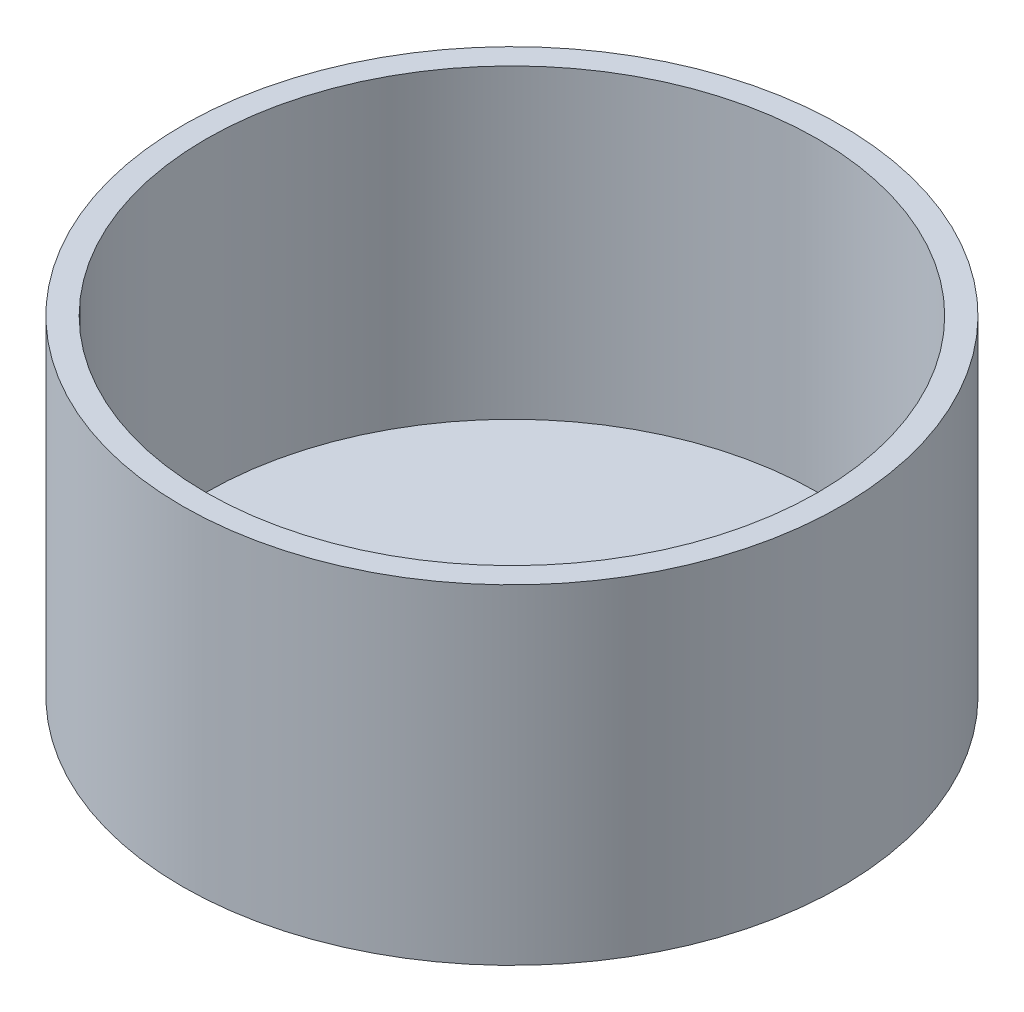
from build123d import *

# Parameters (mm, degrees)
SKETCH1_R           = 70
BOSS_EXTRUDE1_DEPTH = 70
SHELL1_T            = -5


with BuildPart() as part:
    # Sketch1 → Boss-Extrude1 (new body)
    with BuildSketch(Plane(origin=(0, 0, 0), x_dir=(1, 0, 0), z_dir=(0, 1, 0))):
        with Locations(Location((0, 0, 0), (0, 0, 270))):  # turned: the seam where the file's is
            Circle(SKETCH1_R)
    extrude(amount=BOSS_EXTRUDE1_DEPTH)

    # Shell1
    shell1_openings = [part.faces().sort_by_distance(p)[0] for p in [
        (0, 70, 0),
    ]]
    offset(amount=SHELL1_T, openings=shell1_openings, kind=Kind.INTERSECTION)


solid = part.part
